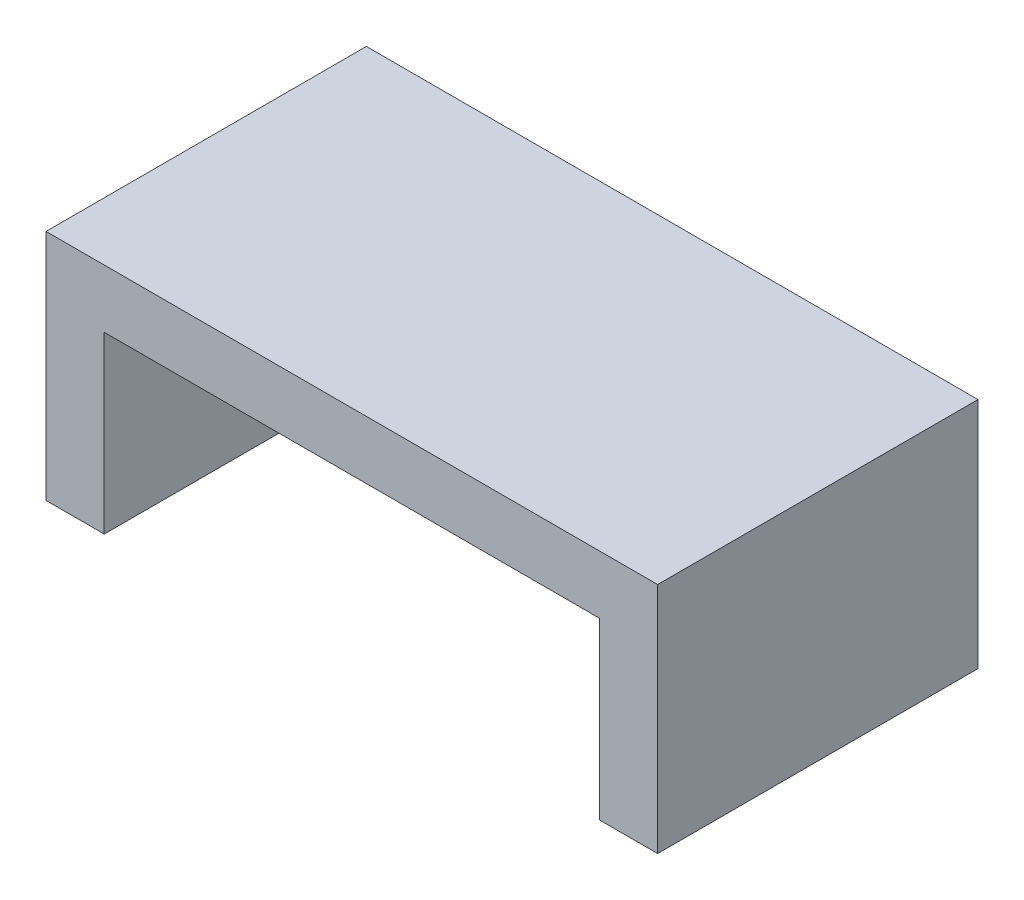
from build123d import *

# Parameters (mm, degrees)
SKETCH1_W           = 42
SKETCH1_H           = 22
BOSS_EXTRUDE1_DEPTH = 16
SHELL2_T            = -4


with BuildPart() as part:
    # Sketch1 → Boss-Extrude1 (new body)
    with BuildSketch(Plane(origin=(0, 0, 0), x_dir=(1, 0, 0), z_dir=(0, 1, 0))):
        with Locations((2.633773294, 1.402399006)):
            Rectangle(SKETCH1_W, SKETCH1_H)
    extrude(amount=BOSS_EXTRUDE1_DEPTH)

    # Shell2
    shell2_openings = [part.faces().sort_by_distance(p)[0] for p in [
        (2.633773294, 0, -1.402399006),
        (2.633773294, 8, -12.402399006),
        (2.633773294, 8, 9.597600994),
    ]]
    offset(amount=SHELL2_T, openings=shell2_openings, kind=Kind.INTERSECTION)


solid = part.part
